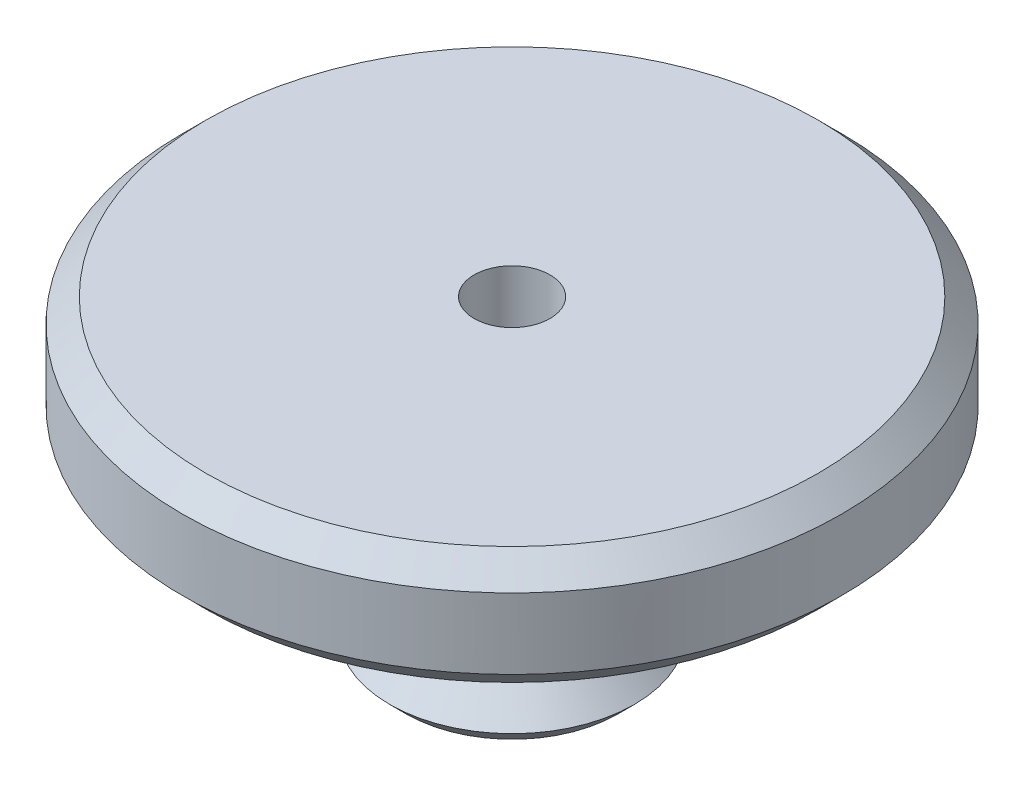
from build123d import *

# Parameters (mm, degrees)
SKETCH_2_R          = 1.61
CUT_EXTRUDE_1_DEPTH = 14.107106781
CHAMFER_1_SIZE      = 0.39
CHAMFER_2_SIZE      = 1


with BuildPart() as part:
    # Эскиз1 → Повернуть1 (revolve)
    with BuildSketch(Plane.XY):
        Polygon((0, 0), (14, 0), (14, -5), (5, -5), (5, -10), (4, -10), (4, -11.2), (5.2, -12.4), (4.492893219, -13.107106781), (2.585786438, -11.2), (2.585786438, -10), (0, -10), align=None)
    revolve(axis=Axis((0, -10, 0), (0, 1, 0)))

    # Эскиз2 → Вырез-Вытянуть1 (cut, through all)
    with BuildSketch(Plane(origin=(0, 0, 0), x_dir=(1, 0, 0), z_dir=(0, 1, 0))):
        Circle(SKETCH_2_R)
    extrude(amount=-CUT_EXTRUDE_1_DEPTH, mode=Mode.SUBTRACT)

    # Фаска1
    chamfer_1_edges = [part.edges().sort_by_distance(p)[0] for p in [
        (-1.61, -10, 0),
    ]]
    chamfer(chamfer_1_edges, length=CHAMFER_1_SIZE)

    # Фаска2
    chamfer_2_edges = [part.edges().sort_by_distance(p)[0] for p in [
        (-14, -5, 0),
        (-14, 0, 0),
    ]]
    chamfer(chamfer_2_edges, length=CHAMFER_2_SIZE)


solid = part.part
